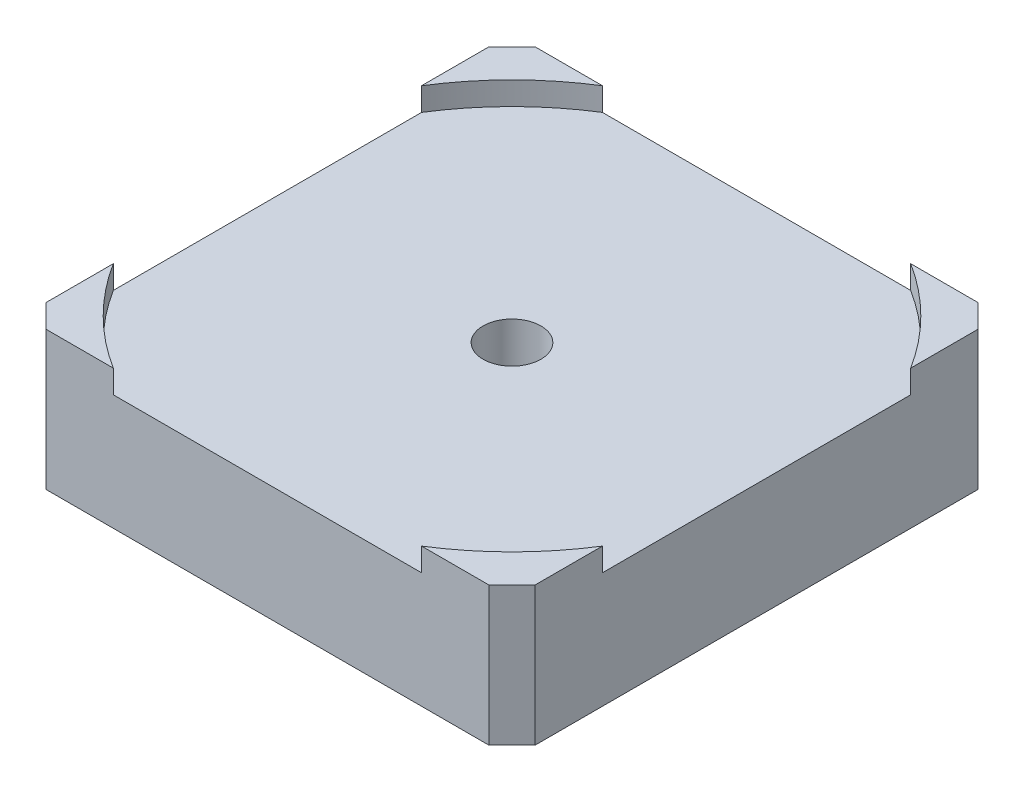
from build123d import *

# Parameters (mm, degrees)
CROQUIS1_W              = 42.3
CROQUIS1_H              = 42.3
SALIENTE_EXTRUIR1_DEPTH = 12
CORTAR_EXTRUIR1_DEPTH   = 2
CHAFL_N1_SIZE           = 2
CROQUIS3_R              = 2.5
CORTAR_EXTRUIR2_DEPTH   = 11


with BuildPart() as part:
    # Croquis1 → Saliente-Extruir1 (new body)
    with BuildSketch(Plane(origin=(0, 0, 0), x_dir=(1, 0, 0), z_dir=(0, 1, 0))):
        Rectangle(CROQUIS1_W, CROQUIS1_H)
    extrude(amount=SALIENTE_EXTRUIR1_DEPTH)

    # Croquis2 → Cortar-Extruir1 (cut)
    with BuildSketch(Plane(origin=(0, 12, 0), x_dir=(1, 0, 0), z_dir=(0, 1, 0))):
        with BuildLine():
            Line((-21.15, 13.329572386), (-21.15, -13.329572386))
            ThreePointArc((-21.15, -13.329572386), (-17.67766953, -17.67766953), (-13.329572386, -21.15))
            Line((-13.329572386, -21.15), (13.329572386, -21.15))
            ThreePointArc((13.329572386, -21.15), (17.67766953, -17.67766953), (21.15, -13.329572386))
            Line((21.15, -13.329572386), (21.15, 13.329572386))
            ThreePointArc((21.15, 13.329572386), (17.67766953, 17.67766953), (13.329572386, 21.15))
            Line((13.329572386, 21.15), (-13.329572386, 21.15))
            ThreePointArc((-13.329572386, 21.15), (-17.67766953, 17.67766953), (-21.15, 13.329572386))
        make_face()
    extrude(amount=-CORTAR_EXTRUIR1_DEPTH, mode=Mode.SUBTRACT)

    # Chaflán1
    chafl_n1_edges = [part.edges().sort_by_distance(p)[0] for p in [
        (21.15, 6, 21.15),
        (-21.15, 6, 21.15),
        (-21.15, 6, -21.15),
        (21.15, 6, -21.15),
    ]]
    chamfer(chafl_n1_edges, length=CHAFL_N1_SIZE)

    # Croquis3 → Cortar-Extruir2 (cut, through all)
    with BuildSketch(Plane(origin=(0, 10, 0), x_dir=(1, 0, 0), z_dir=(0, 1, 0))):
        Circle(CROQUIS3_R)
    extrude(amount=-CORTAR_EXTRUIR2_DEPTH, mode=Mode.SUBTRACT)


solid = part.part
